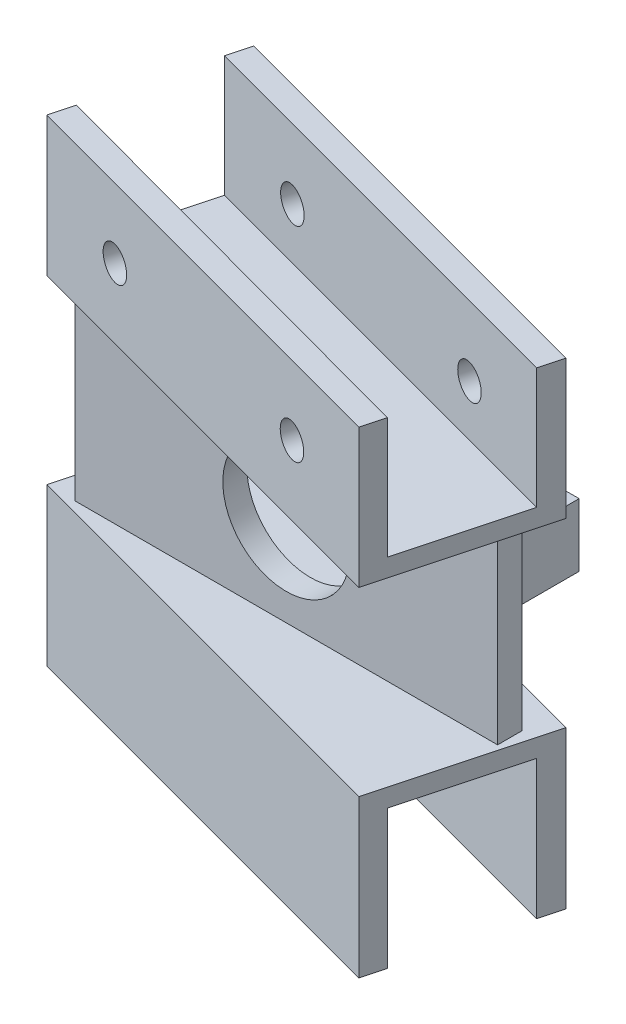
from build123d import *

# Parameters (mm, degrees)
SKETCH1_W           = 70
SKETCH1_H           = 30
SKETCH1_R           = 10.5
BOSS_EXTRUDE1_DEPTH = 4
SKETCH3_W           = 8.150987667
SKETCH3_H           = 10.43538234
SKETCH3_W_2         = 6.820916115
SKETCH3_H_2         = 20
BOSS_EXTRUDE2_DEPTH = 17
SKETCH4_R           = 1
CUT_EXTRUDE1_DEPTH  = 17
BOSS_EXTRUDE4_DEPTH = 3
BOSS_EXTRUDE5_DEPTH = 20
SKETCH10_R          = 2.75
CUT_EXTRUDE2_DEPTH  = 47.267747797
BOSS_EXTRUDE6_DEPTH = 3
BOSS_EXTRUDE7_DEPTH = 23


with BuildPart() as part:
    # Sketch1 → Boss-Extrude1 (new body)
    with BuildSketch(Plane.XY):
        with Locations((35, -15)):
            Rectangle(SKETCH1_W, SKETCH1_H)
        with Locations((35, -15)):
            Circle(SKETCH1_R, mode=Mode.SUBTRACT)
    extrude(amount=BOSS_EXTRUDE1_DEPTH)

    # Sketch3 → Boss-Extrude2 (add)
    with BuildSketch(Plane(origin=(0, 0, 0), x_dir=(-1, 0, 0), z_dir=(0, 0, -1))):
        with Locations((-58.424506167, -14.156074174)):
            Rectangle(SKETCH3_W, SKETCH3_H)
        with Locations((-10.910458058, -15)):
            Rectangle(SKETCH3_W_2, SKETCH3_H_2)
    extrude(amount=BOSS_EXTRUDE2_DEPTH)

    # Sketch4 → Cut-Extrude1 (cut)
    with BuildSketch(Plane(origin=(0, 0, -17), x_dir=(-1, 0, 0), z_dir=(0, 0, -1))):
        with Locations((-58.5, -14.289099526)):
            Circle(SKETCH4_R)
        with Locations((-11.5, -7)):
            Circle(SKETCH4_R)
        with Locations((-11.5, -23)):
            Circle(SKETCH4_R)
    extrude(amount=-CUT_EXTRUDE1_DEPTH, mode=Mode.SUBTRACT)

    # Sketch7 → Boss-Extrude4 (add)
    with BuildSketch(Plane(origin=(0, 0, 0), x_dir=(1, 0, 0), z_dir=(0, 1, 0))):
        Polygon((-4.630368757, -4), (65.950788783, -22.912164164), (73.197722046, 4.133758972), (2.616564506, 23.045923136), align=None)
    extrude(amount=BOSS_EXTRUDE4_DEPTH)

    # Sketch9 → Boss-Extrude5 (add)
    with BuildSketch(Plane(origin=(0, 3, 0), x_dir=(1, 0, 0), z_dir=(0, 1, 0))):
        Polygon((-4.630368757, -4), (65.950788783, -22.912164164), (66.943950204, -19.205635281), (-3.595092577, -0.136296695), align=None)
        Polygon((2.616564506, 23.045923136), (1.581288325, 19.182219831), (72.162445865, 0.270055667), (73.197722046, 4.133758972), align=None)
    extrude(amount=BOSS_EXTRUDE5_DEPTH)

    # Sketch10 → Cut-Extrude2 (cut, through all)
    with BuildSketch(Plane(origin=(5.936757371, 0, -22.156280139), x_dir=(-0.965925826, 0, -0.258819045), z_dir=(0.258819045, 0, -0.965925826))):
        with Locations((-53.953749554, 11.5)):
            Circle(SKETCH10_R)
        with Locations((-12.488324975, 11.5)):
            Circle(SKETCH10_R)
    extrude(amount=-CUT_EXTRUDE2_DEPTH, mode=Mode.SUBTRACT)

    # Sketch5 → Boss-Extrude6 (add)
    with BuildSketch(Plane.XZ.offset(30)):
        Polygon((-4.630368757, 4), (2.616564506, -23.045923136), (73.197722046, -4.133758972), (65.950788783, 22.912164164), align=None)
    extrude(amount=BOSS_EXTRUDE6_DEPTH)

    # Sketch6 → Boss-Extrude7 (add)
    with BuildSketch(Plane.XZ.offset(33)):
        Polygon((-4.630368757, 4), (-3.595092577, 0.136296695), (66.943950204, 19.205635281), (65.950788783, 22.912164164), align=None)
        Polygon((2.616564506, -23.045923136), (73.197722046, -4.133758972), (72.162445865, -0.270055667), (1.581288325, -19.182219831), align=None)
    extrude(amount=BOSS_EXTRUDE7_DEPTH)


solid = part.part
